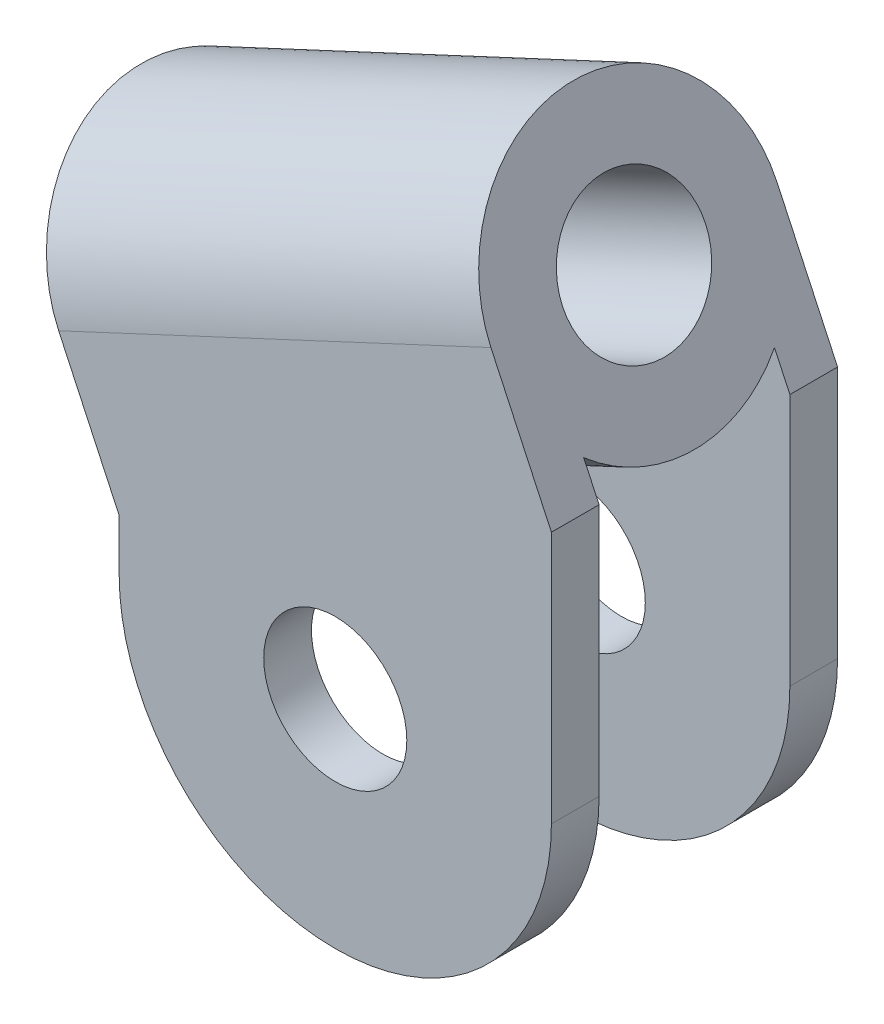
from build123d import *

# Parameters (mm, degrees)
BOSS_EXTRUDE1_START      = 20
BOSS_EXTRUDE1_DEPTH      = 10
BOSS_EXTRUDE2_START      = -20
BOSS_EXTRUDE2_DEPTH      = 10
BOSS_EXTRUDE3_REACH      = 137.843
BOSS_EXTRUDE3_END_RADIUS = 30
SKETCH3_W                = 100
SKETCH3_H                = 10
CUT_EXTRUDE1_DEPTH       = 166.270739546
CUT_EXTRUDE1_DEPTH_BACK  = 166.270739546
SKETCH4_R                = 15
CUT_EXTRUDE2_DEPTH       = 146.587341707
CUT_EXTRUDE2_DEPTH_BACK  = 146.587341707
SKETCH5_R                = 15


with BuildPart() as part:
    # Sketch1 → Revolve1 (revolve)
    with BuildSketch(Plane.XY):
        Polygon((0, 0), (90.630778704, 42.261826174), (77.952230851, 69.451059785), (-12.678547852, 27.189233611), align=None)
    revolve(axis=Axis((0, 0, 0), (0.9063077870366494, 0.4226182617407008, 0)))



with BuildPart() as body_2:
    # Sketch2 → Boss-Extrude1 (new body)
    with BuildSketch(Plane.XY.offset(BOSS_EXTRUDE1_START)):
        with BuildLine():
            Line((103.309326556, 15.072592563), (12.678547852, -27.189233611))
            Line((12.678547852, -27.189233611), (12.678547852, -37.88831917))
            ThreePointArc((12.678547852, -37.88831917), (57.993937204, -83.203708522), (103.309326556, -37.88831917))
            Line((103.309326556, -37.88831917), (103.309326556, 15.072592563))
        make_face()
    extrude(amount=BOSS_EXTRUDE1_DEPTH)


with BuildPart() as body_3:
    # Sketch2_3 → Boss-Extrude2 (new body)
    with BuildSketch(Plane.XY.offset(BOSS_EXTRUDE2_START)):
        with BuildLine():
            Line((12.678547852, -27.189233611), (12.678547852, -37.88831917))
            ThreePointArc((12.678547852, -37.88831917), (57.993937204, -83.203708522), (103.309326556, -37.88831917))
            Line((103.309326556, -37.88831917), (103.309326556, 15.072592563))
            Line((103.309326556, 15.072592563), (12.678547852, -27.189233611))
        make_face()
    extrude(amount=-BOSS_EXTRUDE2_DEPTH)


with BuildPart() as part_1:
    add(part.part)

    add(body_2.part)  # Boss-Extrude3 merges body 2

    add(body_3.part)  # Boss-Extrude3 merges body 3
    # Boss-Extrude3: up to this cylinder (the profile starts outside it)
    boss_extrude3_end = Plane(origin=(45.315389002, 21.130912924, 0), z_dir=(-0.9063077870366494, -0.4226182617407008, 0)) * Cylinder(BOSS_EXTRUDE3_END_RADIUS, 336.686, mode=Mode.PRIVATE)
    # Sketch3 → Boss-Extrude3 (add, up to the surface)
    with BuildSketch(Plane(origin=(12.678547852, -27.189233611, 0), x_dir=(0.9063077870366494, 0.4226182617407009, 0), z_dir=(-0.4226182617407009, 0.9063077870366494, 0)), mode=Mode.PRIVATE) as boss_extrude3_sk1:
        with Locations((50, -25)):
            Rectangle(SKETCH3_W, SKETCH3_H)
    boss_extrude3_tool1 = extrude(boss_extrude3_sk1.sketch, amount=BOSS_EXTRUDE3_REACH, mode=Mode.PRIVATE) - boss_extrude3_end
    add(boss_extrude3_tool1.solids().sort_by_distance((57.993937, -6.058321, 25))[0])
    # Sketch3 → Boss-Extrude3 (add, up to the surface)
    with BuildSketch(Plane(origin=(12.678547852, -27.189233611, 0), x_dir=(0.9063077870366494, 0.4226182617407009, 0), z_dir=(-0.4226182617407009, 0.9063077870366494, 0)), mode=Mode.PRIVATE) as boss_extrude3_sk2:
        with Locations((50, 25)):
            Rectangle(SKETCH3_W, SKETCH3_H)
    boss_extrude3_tool2 = extrude(boss_extrude3_sk2.sketch, amount=BOSS_EXTRUDE3_REACH, mode=Mode.PRIVATE) - boss_extrude3_end
    add(boss_extrude3_tool2.solids().sort_by_distance((57.993937, -6.058321, -25))[0])

    # Sketch4 → Cut-Extrude1 (cut, two sides: drawn at the far end of the back side and taken through both)
    with BuildSketch(Plane(origin=(90.630778704, 42.261826174, 0), x_dir=(0, 0, -1), z_dir=(0.9063077870366494, 0.42261826174070094, 0)).offset(-CUT_EXTRUDE1_DEPTH_BACK)):
        Circle(SKETCH4_R)
    extrude(amount=CUT_EXTRUDE1_DEPTH + CUT_EXTRUDE1_DEPTH_BACK, mode=Mode.SUBTRACT)

    # Sketch5 → Cut-Extrude2 (cut, two sides: drawn at the far end of the back side and taken through both)
    with BuildSketch(Plane.XY.offset(30).offset(-CUT_EXTRUDE2_DEPTH_BACK)):
        with Locations((57.993937204, -37.88831917)):
            Circle(SKETCH5_R)
    extrude(amount=CUT_EXTRUDE2_DEPTH + CUT_EXTRUDE2_DEPTH_BACK, mode=Mode.SUBTRACT)


solid = part_1.part
